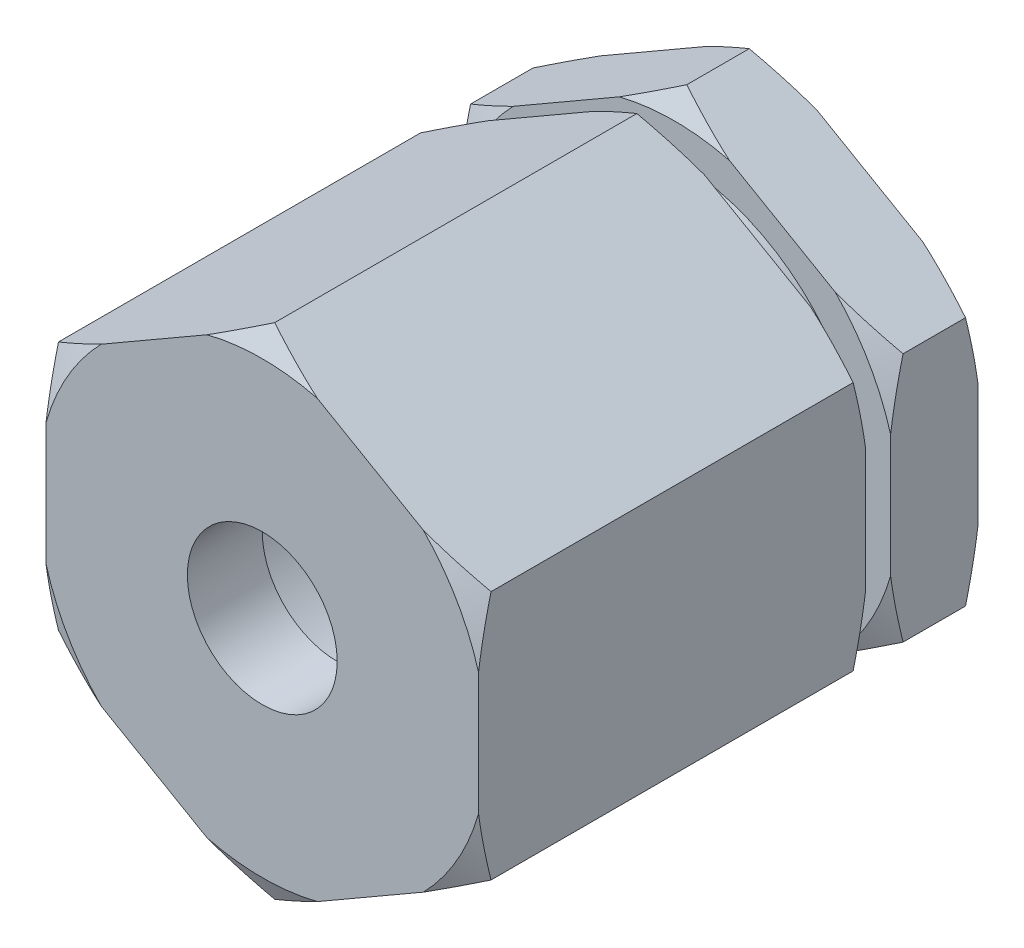
from build123d import *

# Parameters (mm, degrees)
ESBO_O2_R                = 3
RESSALTO_EXTRUS_O1_DEPTH = 20
ESBO_O3_R                = 6
CORTE_EXTRUS_O1_DEPTH    = 17


with BuildPart() as part:
    # Esboço2 → Ressalto-extrusão1 (new body)
    with BuildSketch(Plane.XY):
        Polygon((-8.660254038, 5), (-8.660254038, -5), (0, -10), (8.660254038, -5), (8.660254038, 5), (0, 10), align=None)
        Circle(ESBO_O2_R, mode=Mode.SUBTRACT)
    extrude(amount=RESSALTO_EXTRUS_O1_DEPTH)

    # Esboço3 → Corte-extrusão1 (cut)
    with BuildSketch(Plane(origin=(0, 0, 0), x_dir=(-1, 0, 0), z_dir=(0, 0, -1))):
        Circle(ESBO_O3_R)
    extrude(amount=-CORTE_EXTRUS_O1_DEPTH, mode=Mode.SUBTRACT)

    # Esboço6 → Corte-Revolução3 (revolve, cut)
    with BuildSketch(Plane(origin=(0, 0, 0), x_dir=(1, 0, 0), z_dir=(0, 1, 0))):
        Polygon((-8.660254038, -3.5), (-10.094489548, -3.5), (-10.094489548, -4.5), (-8.660254038, -4.5), (-7.660254038, -4.5), (-7.660254038, -3.5), align=None)
    revolve(axis=Axis((0, 0, 21), (0, 0, -1)), mode=Mode.SUBTRACT)

    # Esboço11 → Corte-Revolução7 (revolve, cut)
    with BuildSketch(Plane(origin=(0, 0, 0), x_dir=(0, 0, -1), z_dir=(1, 0, 0))):
        Polygon((0, 9), (-0.5, 10), (-3, 10), (-3.5, 9), (-4.5, 9), (-5, 10), (-19.5, 10), (-20, 9), (-20, 10.45616239), (0, 10.45616239), align=None)
    revolve(axis=Axis((0, 0, 21), (0, 0, -1)), mode=Mode.SUBTRACT)


solid = part.part
